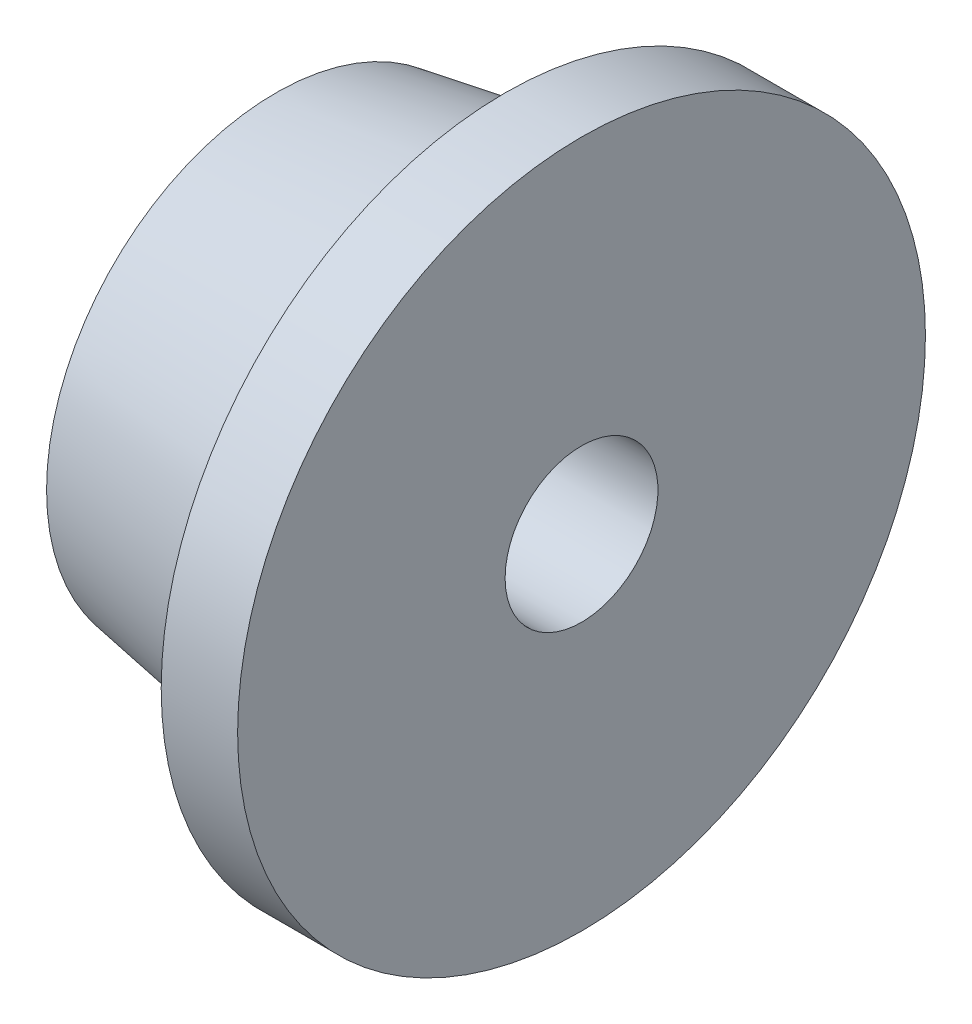
from build123d import *


with BuildPart() as part:
    # Sketch1 → Revolve1 (revolve)
    with BuildSketch(Plane.XY):
        Polygon((0.927471423, 4.5), (1.927471423, 4.5), (1.927471423, 1), (-2.072528577, 1), (-2.072528577, 3), (0.927471423, 3.5), align=None)
    revolve(axis=Axis((-11.471189379, 0, 0), (1, 0, 0)))


solid = part.part
